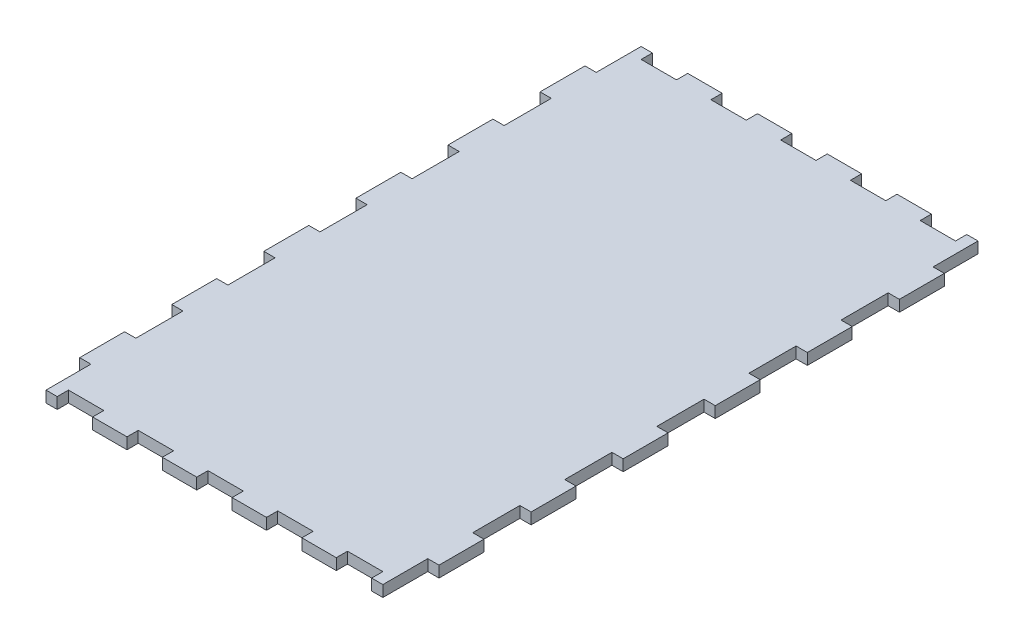
from build123d import *

# Parameters (mm, degrees)
BOSS_EXTRUDE1_DEPTH = 5


with BuildPart() as part:
    # Sketch1 → Boss-Extrude1 (new body)
    with BuildSketch(Plane(origin=(0, 0, 0), x_dir=(1, 0, 0), z_dir=(0, 1, 0))):
        Polygon((-80, 71.5), (-80, 51.5), (-75, 51.5), (-75, 30.5), (-80, 30.5), (-80, 10.5), (-75, 10.5), (-75, -10.5), (-80, -10.5), (-80, -30.5), (-75, -30.5), (-75, -51.5), (-80, -51.5), (-80, -71.5), (-75, -71.5), (-75, -92.5), (-80, -92.5), (-80, -112.5), (-75, -112.5), (-75, -132.5), (-70, -132.5), (-70, -127.5), (-54.25, -127.5), (-54.25, -132.5), (-38.9375, -132.5), (-38.9375, -127.5), (-23.1875, -127.5), (-23.1875, -132.5), (-7.875, -132.5), (-7.875, -127.5), (7.875, -127.5), (7.875, -132.5), (23.1875, -132.5), (23.1875, -127.5), (38.9375, -127.5), (38.9375, -132.5), (54.25, -132.5), (54.25, -127.5), (70, -127.5), (70, -132.5), (75, -132.5), (75, -112.5), (80, -112.5), (80, -92.5), (75, -92.5), (75, -71.5), (80, -71.5), (80, -51.5), (75, -51.5), (75, -30.5), (80, -30.5), (80, -10.5), (75, -10.5), (75, 10.5), (80, 10.5), (80, 30.5), (75, 30.5), (75, 51.5), (80, 51.5), (80, 71.5), (75, 71.5), (75, 92.5), (80, 92.5), (80, 112.5), (75, 112.5), (75, 132.5), (70, 132.5), (70, 127.5), (54.25, 127.5), (54.25, 132.5), (38.9375, 132.5), (38.9375, 127.5), (23.1875, 127.5), (23.1875, 132.5), (7.875, 132.5), (7.875, 127.5), (-7.875, 127.5), (-7.875, 132.5), (-23.1875, 132.5), (-23.1875, 127.5), (-38.9375, 127.5), (-38.9375, 132.5), (-54.25, 132.5), (-54.25, 127.5), (-70, 127.5), (-70, 132.5), (-75, 132.5), (-75, 112.5), (-80, 112.5), (-80, 92.5), (-75, 92.5), (-75, 71.5), align=None)
    extrude(amount=BOSS_EXTRUDE1_DEPTH)


solid = part.part
